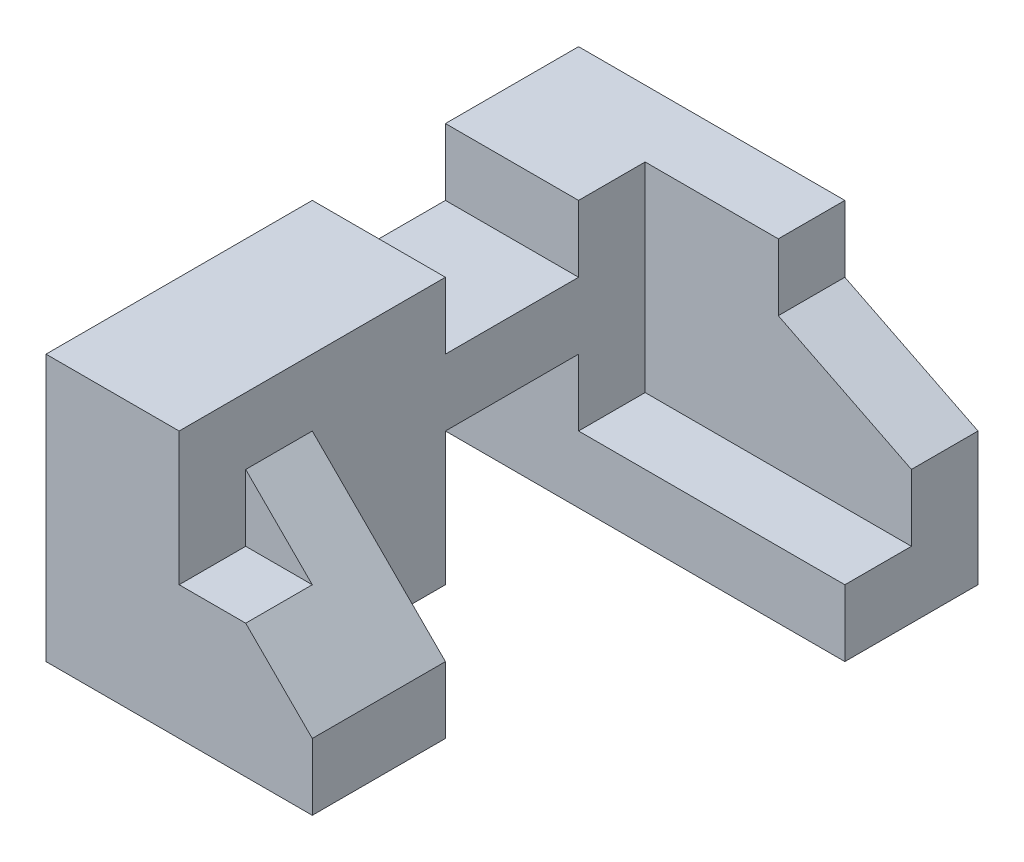
from build123d import *

# Parameters (mm, degrees)
SKETCH1_W           = 6
SKETCH1_H           = 4
BOSS_EXTRUDE1_DEPTH = 8
SKETCH2_W           = 2
SKETCH2_H           = 2
CUT_EXTRUDE1_DEPTH  = 1
SKETCH4_W           = 5
SKETCH4_H           = 3
CUT_EXTRUDE13_DEPTH = 4
SKETCH5_W           = 4
SKETCH5_H           = 1
CUT_EXTRUDE14_DEPTH = 4
SKETCH6_W           = 2
SKETCH6_H           = 2
CUT_EXTRUDE15_DEPTH = 3
CUT_EXTRUDE16_DEPTH = 1
SKETCH8_W           = 1
SKETCH8_H           = 1
CUT_EXTRUDE17_DEPTH = 2
SKETCH10_W          = 2
SKETCH10_H          = 2
CUT_EXTRUDE18_DEPTH = 5
SKETCH12_W          = 2
SKETCH12_H          = 1
CUT_EXTRUDE19_DEPTH = 2
CUT_EXTRUDE20_DEPTH = 2


with BuildPart() as part:
    # Sketch1 → Boss-Extrude1 (new body)
    with BuildSketch(Plane.XY):
        Rectangle(SKETCH1_W, SKETCH1_H)
    extrude(amount=BOSS_EXTRUDE1_DEPTH)

    # Sketch2 → Cut-Extrude1 (cut)
    with BuildSketch(Plane(origin=(0, 2, 0), x_dir=(1, 0, 0), z_dir=(0, 1, 0))):
        with Locations((-2, -3)):
            Rectangle(SKETCH2_W, SKETCH2_H)
    extrude(amount=-CUT_EXTRUDE1_DEPTH, mode=Mode.SUBTRACT)

    # Sketch4 → Cut-Extrude13 (cut)
    with BuildSketch(Plane(origin=(3, 0, 0), x_dir=(0, 0, -1), z_dir=(1, 0, 0))):
        with Locations((-3.5, 0.5)):
            Rectangle(SKETCH4_W, SKETCH4_H)
    extrude(amount=-CUT_EXTRUDE13_DEPTH, mode=Mode.SUBTRACT)

    # Sketch5 → Cut-Extrude14 (cut)
    with BuildSketch(Plane(origin=(3, 0, 0), x_dir=(0, 0, -1), z_dir=(1, 0, 0))):
        with Locations((-4, -1.5)):
            Rectangle(SKETCH5_W, SKETCH5_H)
    extrude(amount=-CUT_EXTRUDE14_DEPTH, mode=Mode.SUBTRACT)

    # Sketch6 → Cut-Extrude15 (cut, through all)
    with BuildSketch(Plane(origin=(-1, 0, 0), x_dir=(0, 0, -1), z_dir=(1, 0, 0))):
        with Locations((-3, -1)):
            Rectangle(SKETCH6_W, SKETCH6_H)
    extrude(amount=-CUT_EXTRUDE15_DEPTH, mode=Mode.SUBTRACT)

    # Sketch7 → Cut-Extrude16 (cut)
    with BuildSketch(Plane(origin=(0, 0, 0), x_dir=(-1, 0, 0), z_dir=(0, 0, -1))):
        Polygon((-1, 2), (-1, 1), (-3, 0), (-3, 2), align=None)
    extrude(amount=-CUT_EXTRUDE16_DEPTH, mode=Mode.SUBTRACT)

    # Sketch8 → Cut-Extrude17 (cut)
    with BuildSketch(Plane(origin=(0, 2, 0), x_dir=(1, 0, 0), z_dir=(0, 1, 0))):
        with Locations((-0.5, -7.5)):
            Rectangle(SKETCH8_W, SKETCH8_H)
    extrude(amount=-CUT_EXTRUDE17_DEPTH, mode=Mode.SUBTRACT)

    # Sketch10 → Cut-Extrude18 (cut, through all)
    with BuildSketch(Plane(origin=(0, 2, 0), x_dir=(1, 0, 0), z_dir=(0, 1, 0))):
        with Locations((2, -7)):
            Rectangle(SKETCH10_W, SKETCH10_H)
    extrude(amount=-CUT_EXTRUDE18_DEPTH, mode=Mode.SUBTRACT)

    # Sketch12 → Cut-Extrude19 (cut)
    with BuildSketch(Plane(origin=(1, 0, 0), x_dir=(0, 0, -1), z_dir=(1, 0, 0))):
        with Locations((-7, 1.5)):
            Rectangle(SKETCH12_W, SKETCH12_H)
    extrude(amount=-CUT_EXTRUDE19_DEPTH, mode=Mode.SUBTRACT)

    # Sketch13 → Cut-Extrude20 (cut)
    with BuildSketch(Plane.XY.offset(8)):
        Polygon((1, -1), (-1, 1), (1, 1), align=None)
    extrude(amount=-CUT_EXTRUDE20_DEPTH, mode=Mode.SUBTRACT)


solid = part.part
